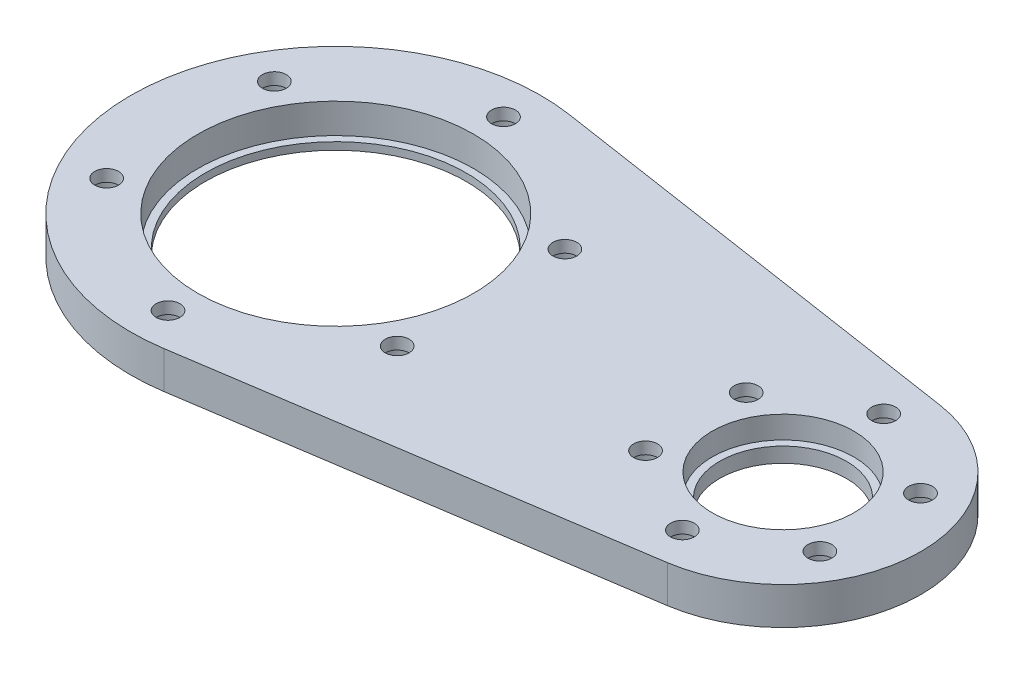
from build123d import *

# Parameters (mm, degrees)
SKETCH_1_R                   = 27.5
SKETCH_1_R_2                 = 17.5
EXTRUDE_1_DEPTH              = 4
SKETCH_2_R                   = 27.5
SKETCH_2_R_2                 = 18.5
EXTRUDE_2_DEPTH              = 5
EXTRUDE_3_DEPTH              = 9
SKETCH_7_R                   = 18.5
CUT_EXTRUDE_4_DEPTH          = 3
SKETCH_13_R                  = 9.5
CUT_EXTRUDE_9_DEPTH          = 7
SKETCH_14_R                  = 8.5
CUT_EXTRUDE_10_DEPTH         = 3
SKETCH_26_W                  = 65.286774434
SKETCH_26_H                  = 13.225755288
CUT_EXTRUDE_11_DEPTH         = 1111
SKETCH_28_R                  = 9.5
SKETCH_28_R_2                = 8.5
EXTRUDE_4_DEPTH              = 2
HOLE_WIZARD_M3_1_D           = 3.2
HOLE_WIZARD_M3_1_CBORE_D     = 6.5
HOLE_WIZARD_M3_1_CBORE_DEPTH = 3.4
PATTERN_CIRCULAR_1_COUNT     = 6
HOLE_WIZARD_M3_2_D           = 3.2
HOLE_WIZARD_M3_2_CBORE_D     = 6.5
HOLE_WIZARD_M3_2_CBORE_DEPTH = 3.4
PATTERN_CIRCULAR_2_COUNT     = 6


with BuildPart() as part:
    # 스케치1 → 보스-돌출1 (new body)
    with BuildSketch(Plane(origin=(0, 0, 0), x_dir=(1, 0, 0), z_dir=(0, 1, 0))):
        Circle(SKETCH_1_R)
        Circle(SKETCH_1_R_2, mode=Mode.SUBTRACT)
    extrude(amount=EXTRUDE_1_DEPTH)

    # 스케치2 → 보스-돌출2 (add)
    with BuildSketch(Plane(origin=(0, 4, 0), x_dir=(1, 0, 0), z_dir=(0, 1, 0))):
        Circle(SKETCH_2_R)
        Circle(SKETCH_2_R_2, mode=Mode.SUBTRACT)
    extrude(amount=EXTRUDE_2_DEPTH)

    # 스케치3 → 보스-돌출3 (add)
    with BuildSketch(Plane(origin=(0, 9, 0), x_dir=(1, 0, 0), z_dir=(0, 1, 0))):
        with BuildLine():
            Line((4.125, 27.188864908), (62.775, 18.290690938))
            ThreePointArc((62.775, 18.290690938), (78.5, 0), (62.775, -18.290690938))
            Line((62.775, -18.290690938), (4.125, -27.188864908))
            ThreePointArc((4.125, -27.188864908), (27.5, 0), (4.125, 27.188864908))
        make_face()
    extrude(amount=-EXTRUDE_3_DEPTH)

    # 스케치7 → 컷-돌출4 (cut)
    with BuildSketch(Plane(origin=(0, 4, 0), x_dir=(1, 0, 0), z_dir=(0, 1, 0))):
        Circle(SKETCH_7_R)
    extrude(amount=-CUT_EXTRUDE_4_DEPTH, mode=Mode.SUBTRACT)

    # 스케치13 → 컷-돌출9 (cut)
    with BuildSketch(Plane.XZ):
        with Locations((60, 0)):
            Circle(SKETCH_13_R)
    extrude(amount=-CUT_EXTRUDE_9_DEPTH, mode=Mode.SUBTRACT)

    # 스케치14 → 컷-돌출10 (cut, through all)
    with BuildSketch(Plane.XZ.offset(-7)):
        with Locations((60, 0)):
            Circle(SKETCH_14_R)
    extrude(amount=-CUT_EXTRUDE_10_DEPTH, mode=Mode.SUBTRACT)

    # 스케치26 → 컷-돌출11 (cut, symmetric)
    with BuildSketch(Plane(origin=(0, 0, 0), x_dir=(0, 0, -1), z_dir=(1, 0, 0))):
        with Locations((-1.179133759, 11.612877644)):
            Rectangle(SKETCH_26_W, SKETCH_26_H)
    extrude(amount=CUT_EXTRUDE_11_DEPTH, both=True, mode=Mode.SUBTRACT)

    # 스케치28 → 보스-돌출4 (add)
    with BuildSketch(Plane.XZ):
        with Locations((60, 0)):
            Circle(SKETCH_28_R)
        with Locations((60, 0)):
            Circle(SKETCH_28_R_2, mode=Mode.SUBTRACT)
    extrude(amount=-EXTRUDE_4_DEPTH)

    # M3 육각 소켓 머리 캡 나사용 카운터보어1 (through all)
    with Locations(Plane(origin=(0, 0, 0), x_dir=(-1, 0, 0), z_dir=(0, -1, 0))):
        with Locations((0, 22.5)):
            hole_wizard_m3_1 = CounterBoreHole(HOLE_WIZARD_M3_1_D / 2, HOLE_WIZARD_M3_1_CBORE_D / 2, HOLE_WIZARD_M3_1_CBORE_DEPTH)

    # 원형 패턴1: M3 육각 소켓 머리 캡 나사용 카운터보어1 ×6 about axis
    pattern_circular_1_axis = Axis((0, 0, 0), (0, 1, 0))
    for i in range(1, PATTERN_CIRCULAR_1_COUNT):
        add(hole_wizard_m3_1.rotate(pattern_circular_1_axis, i * 360 / PATTERN_CIRCULAR_1_COUNT), mode=Mode.SUBTRACT)

    # M3 육각 소켓 머리 캡 나사용 카운터보어2 (through all)
    with Locations(Plane(origin=(0, 0, 0), x_dir=(-1, 0, 0), z_dir=(0, -1, 0))):
        with Locations((-60, 13.5)):
            hole_wizard_m3_2 = CounterBoreHole(HOLE_WIZARD_M3_2_D / 2, HOLE_WIZARD_M3_2_CBORE_D / 2, HOLE_WIZARD_M3_2_CBORE_DEPTH)

    # 원형 패턴2: M3 육각 소켓 머리 캡 나사용 카운터보어2 ×6 about axis
    pattern_circular_2_axis = Axis((60, 0, 0), (0, 1, 0))
    for i in range(1, PATTERN_CIRCULAR_2_COUNT):
        add(hole_wizard_m3_2.rotate(pattern_circular_2_axis, i * 360 / PATTERN_CIRCULAR_2_COUNT), mode=Mode.SUBTRACT)


solid = part.part
